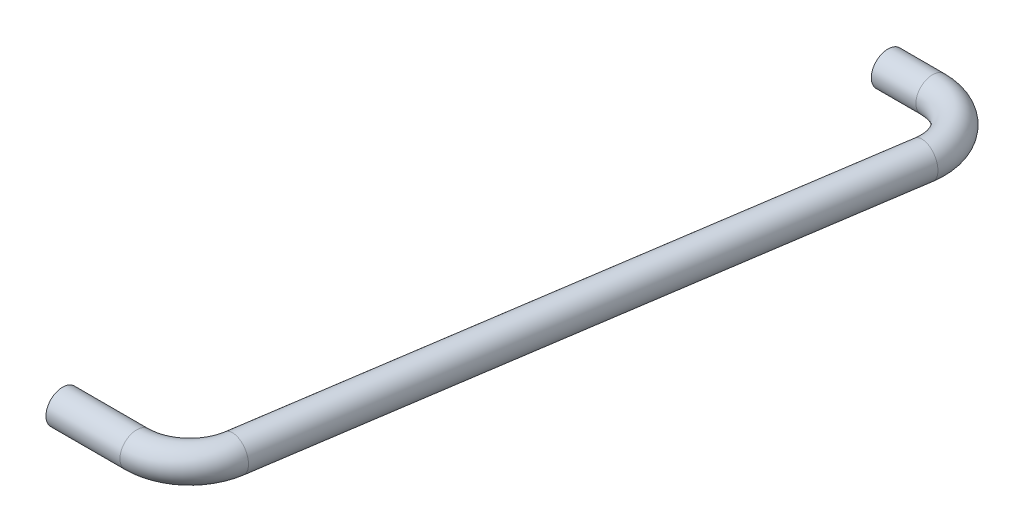
from build123d import *

# Parameters (mm, degrees)
SKETCH2_R = 1.25


with BuildPart() as part:
    # Sweep1: sweep along a path in Sketch1
    with BuildLine(Plane(origin=(0, 0, 0), x_dir=(1, 0, 0), z_dir=(0, 1, 0))) as sweep1_path:
        Line((-8, 0), (-4.649084765, 0))
        ThreePointArc((-4.649084765, 0), (-1.616920267, -1.391172972), (-0.693888418, -4.597010769))
        Line((-0.693888418, -4.597010769), (-7.486341248, -49.597010769))
        ThreePointArc((-7.486341248, -49.597010769), (-8.832710567, -52.032164497), (-11.441537595, -53))
        Line((-11.441537595, -53), (-17, -53))
    # Sketch2 → Sweep1 (sweep)
    with BuildSketch(Plane.ZY.offset(8)):
        Circle(SKETCH2_R)
    sweep(path=sweep1_path.line)


solid = part.part
